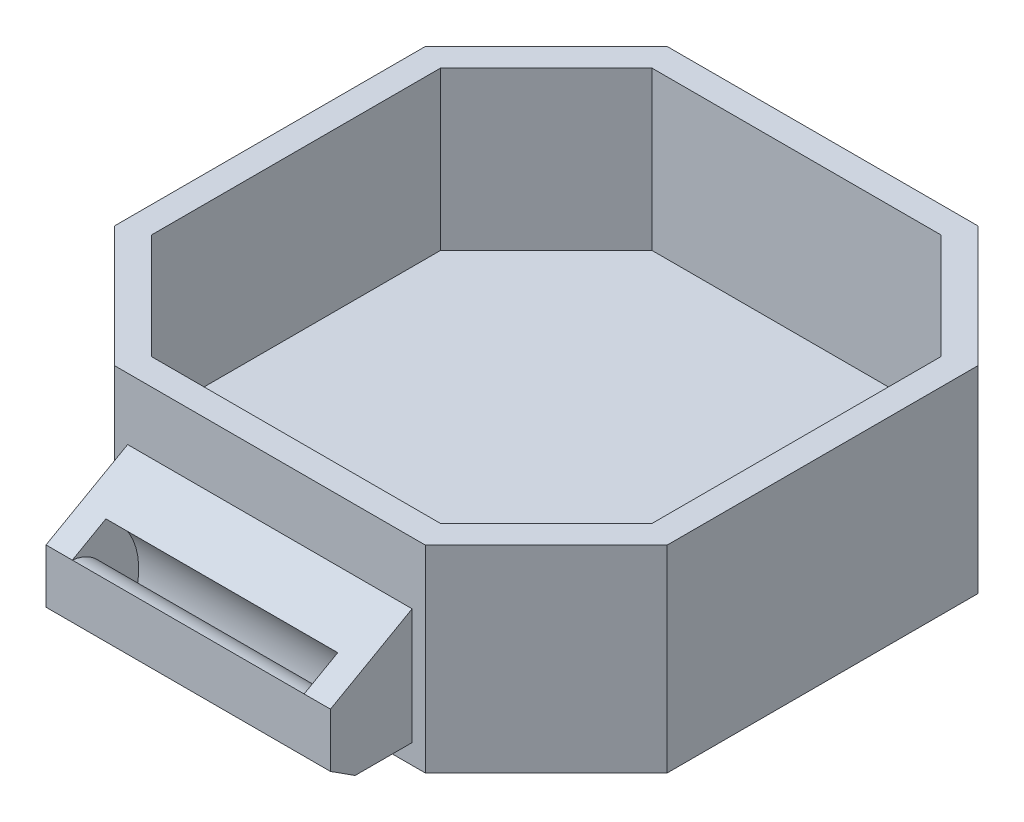
from build123d import *

# Parameters (mm, degrees)
BOSS_EXTRUDE1_DEPTH = 15
CUT_EXTRUDE1_DEPTH  = 12
SKETCH4_W           = 21.61522369
SKETCH4_H           = 10.5
BOSS_EXTRUDE2_DEPTH = 12
CUT_EXTRUDE2_DEPTH  = 32.807611845
CUT_EXTRUDE4_START  = -17.615224
CUT_EXTRUDE4_DEPTH  = 17.615224


with BuildPart() as part:
    # Sketch2 → Boss-Extrude1 (new body)
    with BuildSketch(Plane(origin=(0, 0, 0), x_dir=(1, 0, 0), z_dir=(0, 1, 0))):
        Polygon((-21, 11.807611845), (-21, -11.807611845), (-11.807611845, -21), (11.807611845, -21), (21, -11.807611845), (21, 11.807611845), (11.807611845, 21), (-11.807611845, 21), align=None)
    extrude(amount=BOSS_EXTRUDE1_DEPTH)

    # Sketch3 → Cut-Extrude1 (cut)
    with BuildSketch(Plane(origin=(0, 15, 0), x_dir=(1, 0, 0), z_dir=(0, 1, 0))):
        Polygon((10.97918472, 19), (-10.97918472, 19), (-19, 10.97918472), (-19, -10.97918472), (-10.97918472, -19), (10.97918472, -19), (19, -10.97918472), (19, 10.97918472), align=None)
    extrude(amount=-CUT_EXTRUDE1_DEPTH, mode=Mode.SUBTRACT)

    # Sketch4 → Boss-Extrude2 (add)
    with BuildSketch(Plane.XY.offset(21)):
        with Locations((0, 6.75)):
            Rectangle(SKETCH4_W, SKETCH4_H)
    extrude(amount=BOSS_EXTRUDE2_DEPTH)

    # Sketch5 → Cut-Extrude2 (cut, through all)
    with BuildSketch(Plane(origin=(10.807611845, 0, 0), x_dir=(0, 0, -1), z_dir=(1, 0, 0))):
        Polygon((-25.331702881, 1.5), (-27.204226548, 2.702565985), (-27.204226548, 6.802747117), (-21, 10.304066646), (-21, 12), (-33, 12), (-33, 1.5), align=None)
    extrude(amount=-CUT_EXTRUDE2_DEPTH, mode=Mode.SUBTRACT)

    # Sketch6 → Cut-Extrude4 (cut)
    with BuildSketch(Plane(origin=(8.807611845, 0, 0), x_dir=(0, 0, -1), z_dir=(1, 0, 0)).offset(CUT_EXTRUDE4_START)):
        with BuildLine():
            Line((-27.204226548, 6.802747117), (-24.65218816, 8.242975286))
            ThreePointArc((-24.65218816, 8.242975286), (-22.383701286, 5.248553265), (-22.630570395, 1.5))
            Line((-22.630570395, 1.5), (-25.331702881, 1.5))
            ThreePointArc((-25.331702881, 1.5), (-24.594474047, 4.742322139), (-27.204226548, 6.802747117))
        make_face()
    extrude(amount=CUT_EXTRUDE4_DEPTH, mode=Mode.SUBTRACT)


solid = part.part
